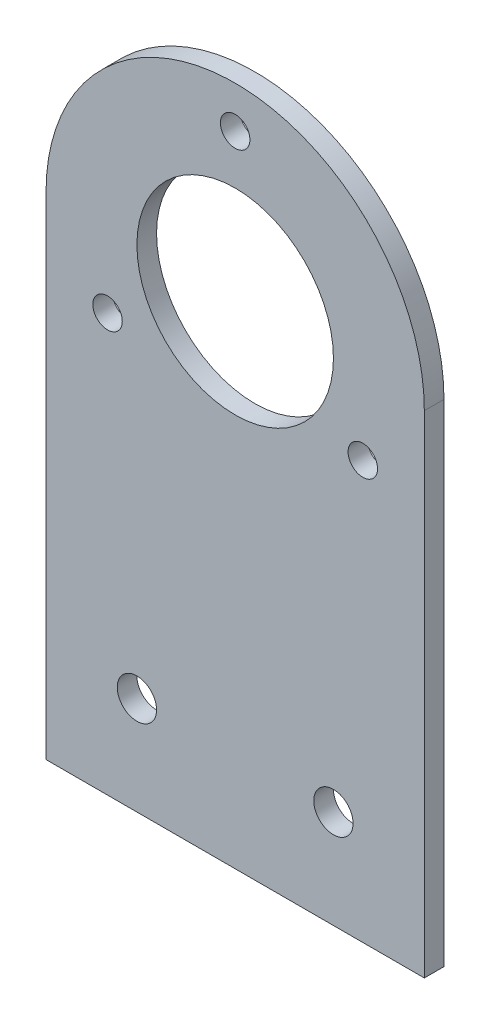
from build123d import *

# Parameters (mm, degrees)
SKETCH1_R           = 1.5
SKETCH1_R_2         = 2
SKETCH1_R_3         = 10
BOSS_EXTRUDE1_DEPTH = 2


with BuildPart() as part:
    # Sketch1 → Boss-Extrude1 (new body)
    with BuildSketch(Plane.XY):
        with BuildLine():
            ThreePointArc((-19.25, 25), (0, 44.25), (19.25, 25))
            Line((19.25, 25), (19.25, -25))
            Line((19.25, -25), (-19.25, -25))
            Line((-19.25, -25), (-19.25, 25))
        make_face()
        with Locations((-12.990381057, 17.5)):
            Circle(SKETCH1_R, mode=Mode.SUBTRACT)
        with Locations((12.990381057, 17.5)):
            Circle(SKETCH1_R, mode=Mode.SUBTRACT)
        with Locations((10, -15)):
            Circle(SKETCH1_R_2, mode=Mode.SUBTRACT)
        with Locations((-10, -15)):
            Circle(SKETCH1_R_2, mode=Mode.SUBTRACT)
        with Locations((0, 40)):
            Circle(SKETCH1_R, mode=Mode.SUBTRACT)
        with Locations((0, 25)):
            Circle(SKETCH1_R_3, mode=Mode.SUBTRACT)
    extrude(amount=BOSS_EXTRUDE1_DEPTH)


solid = part.part
